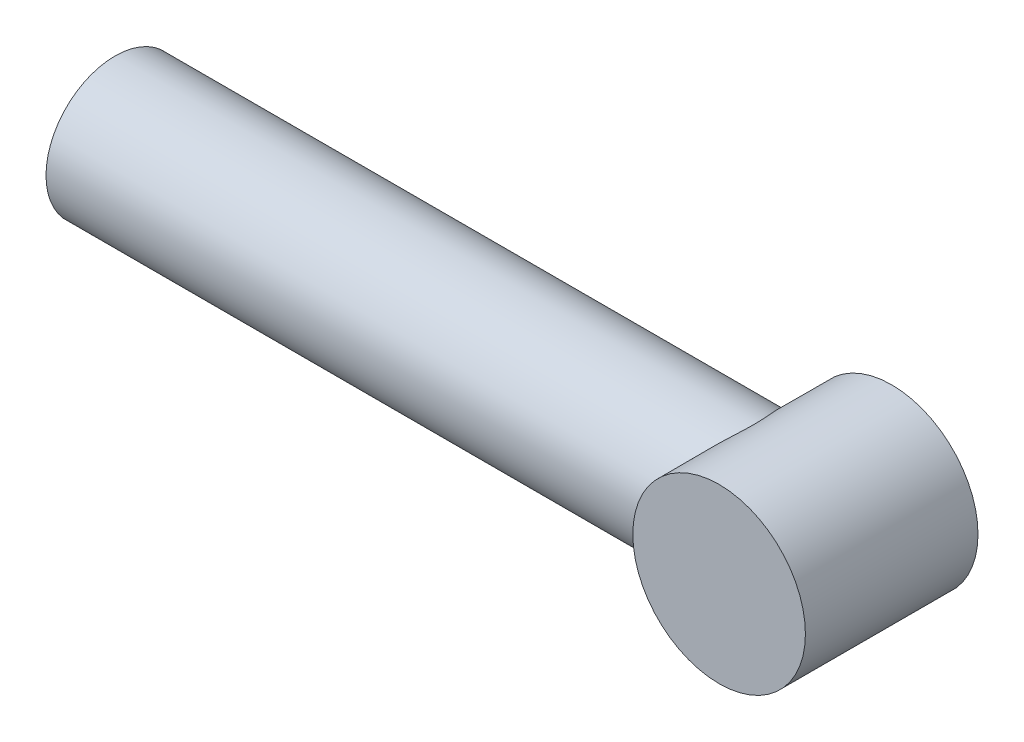
from build123d import *

# Parameters (mm, degrees)
SKETCH_1_R      = 40
EXTRUDE_1_DEPTH = 200
SKETCH_2_R      = 50
EXTRUDE_2_DEPTH = 50


with BuildPart() as part:
    # 草图1 → 凸台-拉伸1 (new body, symmetric)
    with BuildSketch(Plane(origin=(0, 0, 0), x_dir=(0, 0, -1), z_dir=(1, 0, 0))):
        Circle(SKETCH_1_R)
    extrude(amount=EXTRUDE_1_DEPTH, both=True)

    # 草图2 → 凸台-拉伸2 (add, symmetric)
    with BuildSketch(Plane.XY):
        with Locations((200, 0)):
            Circle(SKETCH_2_R)
    extrude(amount=EXTRUDE_2_DEPTH, both=True)


solid = part.part
